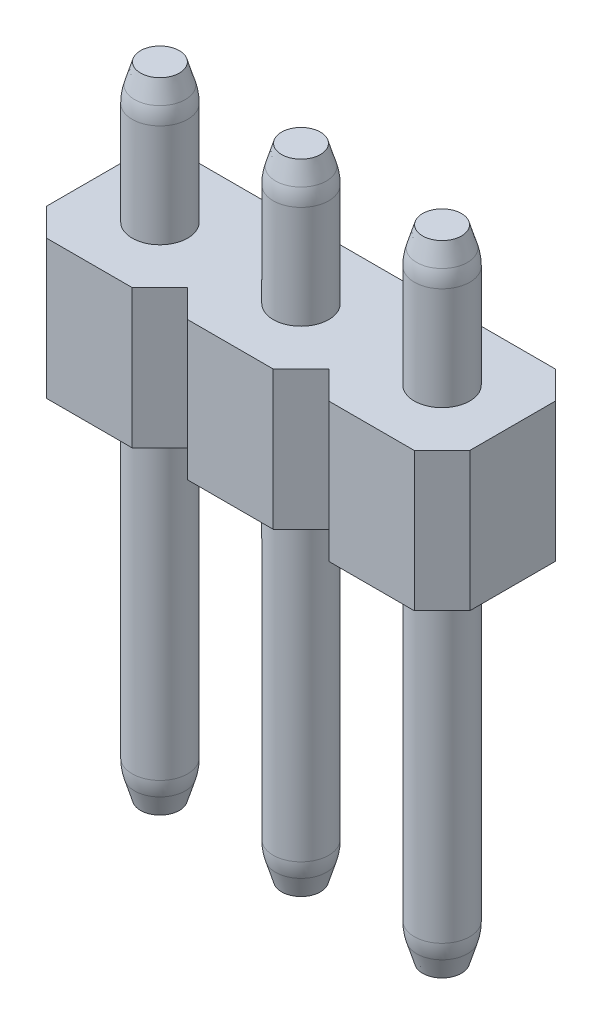
from build123d import *

# Parameters (mm, degrees)
SKETCH1_R               = 0.5
BOSS_EXTRUDE1_DEPTH     = 11.5
BOSS_EXTRUDE1_2_DEPTH   = 11.5
BOSS_EXTRUDE1_3_DEPTH   = 11.5
BOSS_EXTRUDE1_4_DEPTH   = 11.5
BOSS_EXTRUDE1_5_DEPTH   = 11.5
BOSS_EXTRUDE1_6_DEPTH   = 11.5
BOSS_EXTRUDE1_7_DEPTH   = 11.5
BOSS_EXTRUDE1_8_DEPTH   = 11.5
BOSS_EXTRUDE1_9_DEPTH   = 11.5
BOSS_EXTRUDE1_10_DEPTH  = 11.5
BOSS_EXTRUDE1_11_DEPTH  = 11.5
BOSS_EXTRUDE1_12_DEPTH  = 11.5
BOSS_EXTRUDE1_13_DEPTH  = 11.5
BOSS_EXTRUDE1_14_DEPTH  = 11.5
BOSS_EXTRUDE1_15_DEPTH  = 11.5
BOSS_EXTRUDE1_16_DEPTH  = 11.5
BOSS_EXTRUDE2_DEPTH     = 2.5
CHAMFER1_SIZE           = 0.5
CHAMFER1_SIZE2          = 0.15
CHAMFER1_PART_2_SIZE    = 0.5
CHAMFER1_PART_2_SIZE2   = 0.15
CHAMFER1_PART_3_SIZE    = 0.5
CHAMFER1_PART_3_SIZE2   = 0.15
CHAMFER1_PART_4_SIZE    = 0.5
CHAMFER1_PART_4_SIZE2   = 0.15
CHAMFER1_PART_5_SIZE    = 0.5
CHAMFER1_PART_5_SIZE2   = 0.15
CHAMFER1_PART_6_SIZE    = 0.5
CHAMFER1_PART_6_SIZE2   = 0.15
CHAMFER1_PART_7_SIZE    = 0.5
CHAMFER1_PART_7_SIZE2   = 0.15
CHAMFER1_PART_8_SIZE    = 0.5
CHAMFER1_PART_8_SIZE2   = 0.15
CHAMFER1_PART_9_SIZE    = 0.5
CHAMFER1_PART_9_SIZE2   = 0.15
CHAMFER1_PART_10_SIZE   = 0.5
CHAMFER1_PART_10_SIZE2  = 0.15
CHAMFER1_PART_11_SIZE   = 0.5
CHAMFER1_PART_11_SIZE2  = 0.15
CHAMFER1_PART_12_SIZE   = 0.5
CHAMFER1_PART_12_SIZE2  = 0.15
CHAMFER1_PART_13_SIZE   = 0.5
CHAMFER1_PART_13_SIZE2  = 0.15
CHAMFER1_PART_14_SIZE   = 0.5
CHAMFER1_PART_14_SIZE2  = 0.15
CHAMFER1_PART_15_SIZE   = 0.5
CHAMFER1_PART_15_SIZE2  = 0.15
CHAMFER1_PART_16_SIZE   = 0.5
CHAMFER1_PART_16_SIZE2  = 0.15
FILLET1_R               = 1
CHAMFER2_SIZE           = 0.15
CHAMFER2_SIZE2          = 0.5
CHAMFER2_PART_2_SIZE    = 0.15
CHAMFER2_PART_2_SIZE2   = 0.5
CHAMFER2_PART_3_SIZE    = 0.15
CHAMFER2_PART_3_SIZE2   = 0.5
CHAMFER2_PART_4_SIZE    = 0.15
CHAMFER2_PART_4_SIZE2   = 0.5
CHAMFER2_PART_5_SIZE    = 0.15
CHAMFER2_PART_5_SIZE2   = 0.5
CHAMFER2_PART_6_SIZE    = 0.15
CHAMFER2_PART_6_SIZE2   = 0.5
CHAMFER2_PART_7_SIZE    = 0.15
CHAMFER2_PART_7_SIZE2   = 0.5
CHAMFER2_PART_8_SIZE    = 0.15
CHAMFER2_PART_8_SIZE2   = 0.5
CHAMFER2_PART_9_SIZE    = 0.15
CHAMFER2_PART_9_SIZE2   = 0.5
CHAMFER2_PART_10_SIZE   = 0.15
CHAMFER2_PART_10_SIZE2  = 0.5
CHAMFER2_PART_11_SIZE   = 0.15
CHAMFER2_PART_11_SIZE2  = 0.5
CHAMFER2_PART_12_SIZE   = 0.15
CHAMFER2_PART_12_SIZE2  = 0.5
CHAMFER2_PART_13_SIZE   = 0.15
CHAMFER2_PART_13_SIZE2  = 0.5
CHAMFER2_PART_14_SIZE   = 0.15
CHAMFER2_PART_14_SIZE2  = 0.5
CHAMFER2_PART_15_SIZE   = 0.15
CHAMFER2_PART_15_SIZE2  = 0.5
CHAMFER2_PART_16_SIZE   = 0.15
CHAMFER2_PART_16_SIZE2  = 0.5
FILLET2_R               = 1
CUT_EXTRUDE1_DEPTH      = 1
CUT_EXTRUDE1_DEPTH_BACK = 3.54


with BuildPart() as part:
    # Sketch1 → Boss-Extrude1 (new body)
    with BuildSketch(Plane(origin=(0, 0, 0), x_dir=(1, 0, 0), z_dir=(0, 1, 0))):
        Circle(SKETCH1_R)
    extrude(amount=BOSS_EXTRUDE1_DEPTH)



with BuildPart() as body_2:
    # Sketch1 → Boss-Extrude1 2 (new body)
    with BuildSketch(Plane(origin=(0, 0, 0), x_dir=(1, 0, 0), z_dir=(0, 1, 0))):
        with Locations((2.54, 0)):
            Circle(SKETCH1_R)
    extrude(amount=BOSS_EXTRUDE1_2_DEPTH)


with BuildPart() as body_3:
    # Sketch1 → Boss-Extrude1 3 (new body)
    with BuildSketch(Plane(origin=(0, 0, 0), x_dir=(1, 0, 0), z_dir=(0, 1, 0))):
        with Locations((5.08, 0)):
            Circle(SKETCH1_R)
    extrude(amount=BOSS_EXTRUDE1_3_DEPTH)


with BuildPart() as body_4:
    # Sketch1 → Boss-Extrude1 4 (new body)
    with BuildSketch(Plane(origin=(0, 0, 0), x_dir=(1, 0, 0), z_dir=(0, 1, 0))):
        with Locations((7.62, 0)):
            Circle(SKETCH1_R)
    extrude(amount=BOSS_EXTRUDE1_4_DEPTH)


with BuildPart() as body_5:
    # Sketch1 → Boss-Extrude1 5 (new body)
    with BuildSketch(Plane(origin=(0, 0, 0), x_dir=(1, 0, 0), z_dir=(0, 1, 0))):
        with Locations((10.16, 0)):
            Circle(SKETCH1_R)
    extrude(amount=BOSS_EXTRUDE1_5_DEPTH)


with BuildPart() as body_6:
    # Sketch1 → Boss-Extrude1 6 (new body)
    with BuildSketch(Plane(origin=(0, 0, 0), x_dir=(1, 0, 0), z_dir=(0, 1, 0))):
        with Locations((12.7, 0)):
            Circle(SKETCH1_R)
    extrude(amount=BOSS_EXTRUDE1_6_DEPTH)


with BuildPart() as body_7:
    # Sketch1 → Boss-Extrude1 7 (new body)
    with BuildSketch(Plane(origin=(0, 0, 0), x_dir=(1, 0, 0), z_dir=(0, 1, 0))):
        with Locations((15.24, 0)):
            Circle(SKETCH1_R)
    extrude(amount=BOSS_EXTRUDE1_7_DEPTH)


with BuildPart() as body_8:
    # Sketch1 → Boss-Extrude1 8 (new body)
    with BuildSketch(Plane(origin=(0, 0, 0), x_dir=(1, 0, 0), z_dir=(0, 1, 0))):
        with Locations((17.78, 0)):
            Circle(SKETCH1_R)
    extrude(amount=BOSS_EXTRUDE1_8_DEPTH)


with BuildPart() as body_9:
    # Sketch1 → Boss-Extrude1 9 (new body)
    with BuildSketch(Plane(origin=(0, 0, 0), x_dir=(1, 0, 0), z_dir=(0, 1, 0))):
        with Locations((20.32, 0)):
            Circle(SKETCH1_R)
    extrude(amount=BOSS_EXTRUDE1_9_DEPTH)


with BuildPart() as body_10:
    # Sketch1 → Boss-Extrude1 10 (new body)
    with BuildSketch(Plane(origin=(0, 0, 0), x_dir=(1, 0, 0), z_dir=(0, 1, 0))):
        with Locations((22.86, 0)):
            Circle(SKETCH1_R)
    extrude(amount=BOSS_EXTRUDE1_10_DEPTH)


with BuildPart() as body_11:
    # Sketch1 → Boss-Extrude1 11 (new body)
    with BuildSketch(Plane(origin=(0, 0, 0), x_dir=(1, 0, 0), z_dir=(0, 1, 0))):
        with Locations((25.4, 0)):
            Circle(SKETCH1_R)
    extrude(amount=BOSS_EXTRUDE1_11_DEPTH)


with BuildPart() as body_12:
    # Sketch1 → Boss-Extrude1 12 (new body)
    with BuildSketch(Plane(origin=(0, 0, 0), x_dir=(1, 0, 0), z_dir=(0, 1, 0))):
        with Locations((27.94, 0)):
            Circle(SKETCH1_R)
    extrude(amount=BOSS_EXTRUDE1_12_DEPTH)


with BuildPart() as body_13:
    # Sketch1 → Boss-Extrude1 13 (new body)
    with BuildSketch(Plane(origin=(0, 0, 0), x_dir=(1, 0, 0), z_dir=(0, 1, 0))):
        with Locations((30.48, 0)):
            Circle(SKETCH1_R)
    extrude(amount=BOSS_EXTRUDE1_13_DEPTH)


with BuildPart() as body_14:
    # Sketch1 → Boss-Extrude1 14 (new body)
    with BuildSketch(Plane(origin=(0, 0, 0), x_dir=(1, 0, 0), z_dir=(0, 1, 0))):
        with Locations((33.02, 0)):
            Circle(SKETCH1_R)
    extrude(amount=BOSS_EXTRUDE1_14_DEPTH)


with BuildPart() as body_15:
    # Sketch1 → Boss-Extrude1 15 (new body)
    with BuildSketch(Plane(origin=(0, 0, 0), x_dir=(1, 0, 0), z_dir=(0, 1, 0))):
        with Locations((35.56, 0)):
            Circle(SKETCH1_R)
    extrude(amount=BOSS_EXTRUDE1_15_DEPTH)


with BuildPart() as body_16:
    # Sketch1 → Boss-Extrude1 16 (new body)
    with BuildSketch(Plane(origin=(0, 0, 0), x_dir=(1, 0, 0), z_dir=(0, 1, 0))):
        with Locations((38.1, 0)):
            Circle(SKETCH1_R)
    extrude(amount=BOSS_EXTRUDE1_16_DEPTH)


with BuildPart() as part_1:
    add(part.part)

    add(body_2.part)  # Boss-Extrude2 merges body 2

    add(body_3.part)  # Boss-Extrude2 merges body 3

    add(body_4.part)  # Boss-Extrude2 merges body 4

    add(body_5.part)  # Boss-Extrude2 merges body 5

    add(body_6.part)  # Boss-Extrude2 merges body 6

    add(body_7.part)  # Boss-Extrude2 merges body 7

    add(body_8.part)  # Boss-Extrude2 merges body 8

    add(body_9.part)  # Boss-Extrude2 merges body 9

    add(body_10.part)  # Boss-Extrude2 merges body 10

    add(body_11.part)  # Boss-Extrude2 merges body 11

    add(body_12.part)  # Boss-Extrude2 merges body 12

    add(body_13.part)  # Boss-Extrude2 merges body 13

    add(body_14.part)  # Boss-Extrude2 merges body 14

    add(body_15.part)  # Boss-Extrude2 merges body 15

    add(body_16.part)  # Boss-Extrude2 merges body 16
    # Sketch2 → Boss-Extrude2 (add)
    with BuildSketch(Plane(origin=(0, 6.5, 0), x_dir=(1, 0, 0), z_dir=(0, 1, 0))):
        Polygon((-1.27, 0.77), (-0.77, 1.27), (0.77, 1.27), (1.27, 0.77), (1.77, 1.27), (3.31, 1.27), (3.81, 0.77), (4.31, 1.27), (5.85, 1.27), (6.35, 0.77), (6.85, 1.27), (8.39, 1.27), (8.89, 0.77), (9.39, 1.27), (10.93, 1.27), (11.43, 0.77), (11.93, 1.27), (13.47, 1.27), (13.97, 0.77), (14.47, 1.27), (16.01, 1.27), (16.51, 0.77), (17.01, 1.27), (18.55, 1.27), (19.05, 0.77), (19.55, 1.27), (21.09, 1.27), (21.59, 0.77), (22.09, 1.27), (23.63, 1.27), (24.13, 0.77), (24.63, 1.27), (26.17, 1.27), (26.67, 0.77), (27.17, 1.27), (28.71, 1.27), (29.21, 0.77), (29.71, 1.27), (31.25, 1.27), (31.75, 0.77), (32.25, 1.27), (33.79, 1.27), (34.29, 0.77), (34.79, 1.27), (36.33, 1.27), (36.83, 0.77), (37.33, 1.27), (38.87, 1.27), (39.37, 0.77), (39.37, -0.77), (38.87, -1.27), (37.33, -1.27), (36.83, -0.77), (36.33, -1.27), (34.79, -1.27), (34.29, -0.77), (33.79, -1.27), (32.25, -1.27), (31.75, -0.77), (31.25, -1.27), (29.71, -1.27), (29.21, -0.77), (28.71, -1.27), (27.17, -1.27), (26.67, -0.77), (26.17, -1.27), (24.63, -1.27), (24.13, -0.77), (23.63, -1.27), (22.09, -1.27), (21.59, -0.77), (21.09, -1.27), (19.55, -1.27), (19.05, -0.77), (18.55, -1.27), (17.01, -1.27), (16.51, -0.77), (16.01, -1.27), (14.47, -1.27), (13.97, -0.77), (13.47, -1.27), (11.93, -1.27), (11.43, -0.77), (10.93, -1.27), (9.39, -1.27), (8.89, -0.77), (8.39, -1.27), (6.85, -1.27), (6.35, -0.77), (5.85, -1.27), (4.31, -1.27), (3.81, -0.77), (3.31, -1.27), (1.77, -1.27), (1.27, -0.77), (0.77, -1.27), (-0.77, -1.27), (-1.27, -0.77), align=None)
    extrude(amount=BOSS_EXTRUDE2_DEPTH)

    # Chamfer1
    chamfer1_edges = [part_1.edges().sort_by_distance(p)[0] for p in [
        (2.04, 11.5, 0),
    ]]
    chamfer1_side = [part_1.faces().sort_by_distance(p)[0] for p in [
        (2.04, 10.25, 0),
    ]]
    chamfer(chamfer1_edges, length=CHAMFER1_SIZE, length2=CHAMFER1_SIZE2, reference=chamfer1_side[0])

    # Chamfer1 part 2
    chamfer1_part_2_edges = [part_1.edges().sort_by_distance(p)[0] for p in [
        (4.58, 11.5, 0),
    ]]
    chamfer1_part_2_side = [part_1.faces().sort_by_distance(p)[0] for p in [
        (4.58, 10.25, 0),
    ]]
    chamfer(chamfer1_part_2_edges, length=CHAMFER1_PART_2_SIZE, length2=CHAMFER1_PART_2_SIZE2, reference=chamfer1_part_2_side[0])

    # Chamfer1 part 3
    chamfer1_part_3_edges = [part_1.edges().sort_by_distance(p)[0] for p in [
        (7.12, 11.5, 0),
    ]]
    chamfer1_part_3_side = [part_1.faces().sort_by_distance(p)[0] for p in [
        (7.12, 10.25, 0),
    ]]
    chamfer(chamfer1_part_3_edges, length=CHAMFER1_PART_3_SIZE, length2=CHAMFER1_PART_3_SIZE2, reference=chamfer1_part_3_side[0])

    # Chamfer1 part 4
    chamfer1_part_4_edges = [part_1.edges().sort_by_distance(p)[0] for p in [
        (9.66, 11.5, 0),
    ]]
    chamfer1_part_4_side = [part_1.faces().sort_by_distance(p)[0] for p in [
        (9.66, 10.25, 0),
    ]]
    chamfer(chamfer1_part_4_edges, length=CHAMFER1_PART_4_SIZE, length2=CHAMFER1_PART_4_SIZE2, reference=chamfer1_part_4_side[0])

    # Chamfer1 part 5
    chamfer1_part_5_edges = [part_1.edges().sort_by_distance(p)[0] for p in [
        (12.2, 11.5, 0),
    ]]
    chamfer1_part_5_side = [part_1.faces().sort_by_distance(p)[0] for p in [
        (12.2, 10.25, 0),
    ]]
    chamfer(chamfer1_part_5_edges, length=CHAMFER1_PART_5_SIZE, length2=CHAMFER1_PART_5_SIZE2, reference=chamfer1_part_5_side[0])

    # Chamfer1 part 6
    chamfer1_part_6_edges = [part_1.edges().sort_by_distance(p)[0] for p in [
        (14.74, 11.5, 0),
    ]]
    chamfer1_part_6_side = [part_1.faces().sort_by_distance(p)[0] for p in [
        (14.74, 10.25, 0),
    ]]
    chamfer(chamfer1_part_6_edges, length=CHAMFER1_PART_6_SIZE, length2=CHAMFER1_PART_6_SIZE2, reference=chamfer1_part_6_side[0])

    # Chamfer1 part 7
    chamfer1_part_7_edges = [part_1.edges().sort_by_distance(p)[0] for p in [
        (17.28, 11.5, 0),
    ]]
    chamfer1_part_7_side = [part_1.faces().sort_by_distance(p)[0] for p in [
        (17.28, 10.25, 0),
    ]]
    chamfer(chamfer1_part_7_edges, length=CHAMFER1_PART_7_SIZE, length2=CHAMFER1_PART_7_SIZE2, reference=chamfer1_part_7_side[0])

    # Chamfer1 part 8
    chamfer1_part_8_edges = [part_1.edges().sort_by_distance(p)[0] for p in [
        (19.82, 11.5, 0),
    ]]
    chamfer1_part_8_side = [part_1.faces().sort_by_distance(p)[0] for p in [
        (19.82, 10.25, 0),
    ]]
    chamfer(chamfer1_part_8_edges, length=CHAMFER1_PART_8_SIZE, length2=CHAMFER1_PART_8_SIZE2, reference=chamfer1_part_8_side[0])

    # Chamfer1 part 9
    chamfer1_part_9_edges = [part_1.edges().sort_by_distance(p)[0] for p in [
        (22.36, 11.5, 0),
    ]]
    chamfer1_part_9_side = [part_1.faces().sort_by_distance(p)[0] for p in [
        (22.36, 10.25, 0),
    ]]
    chamfer(chamfer1_part_9_edges, length=CHAMFER1_PART_9_SIZE, length2=CHAMFER1_PART_9_SIZE2, reference=chamfer1_part_9_side[0])

    # Chamfer1 part 10
    chamfer1_part_10_edges = [part_1.edges().sort_by_distance(p)[0] for p in [
        (24.9, 11.5, 0),
    ]]
    chamfer1_part_10_side = [part_1.faces().sort_by_distance(p)[0] for p in [
        (24.9, 10.25, 0),
    ]]
    chamfer(chamfer1_part_10_edges, length=CHAMFER1_PART_10_SIZE, length2=CHAMFER1_PART_10_SIZE2, reference=chamfer1_part_10_side[0])

    # Chamfer1 part 11
    chamfer1_part_11_edges = [part_1.edges().sort_by_distance(p)[0] for p in [
        (27.44, 11.5, 0),
    ]]
    chamfer1_part_11_side = [part_1.faces().sort_by_distance(p)[0] for p in [
        (27.44, 10.25, 0),
    ]]
    chamfer(chamfer1_part_11_edges, length=CHAMFER1_PART_11_SIZE, length2=CHAMFER1_PART_11_SIZE2, reference=chamfer1_part_11_side[0])

    # Chamfer1 part 12
    chamfer1_part_12_edges = [part_1.edges().sort_by_distance(p)[0] for p in [
        (29.98, 11.5, 0),
    ]]
    chamfer1_part_12_side = [part_1.faces().sort_by_distance(p)[0] for p in [
        (29.98, 10.25, 0),
    ]]
    chamfer(chamfer1_part_12_edges, length=CHAMFER1_PART_12_SIZE, length2=CHAMFER1_PART_12_SIZE2, reference=chamfer1_part_12_side[0])

    # Chamfer1 part 13
    chamfer1_part_13_edges = [part_1.edges().sort_by_distance(p)[0] for p in [
        (32.52, 11.5, 0),
    ]]
    chamfer1_part_13_side = [part_1.faces().sort_by_distance(p)[0] for p in [
        (32.52, 10.25, 0),
    ]]
    chamfer(chamfer1_part_13_edges, length=CHAMFER1_PART_13_SIZE, length2=CHAMFER1_PART_13_SIZE2, reference=chamfer1_part_13_side[0])

    # Chamfer1 part 14
    chamfer1_part_14_edges = [part_1.edges().sort_by_distance(p)[0] for p in [
        (35.06, 11.5, 0),
    ]]
    chamfer1_part_14_side = [part_1.faces().sort_by_distance(p)[0] for p in [
        (35.06, 10.25, 0),
    ]]
    chamfer(chamfer1_part_14_edges, length=CHAMFER1_PART_14_SIZE, length2=CHAMFER1_PART_14_SIZE2, reference=chamfer1_part_14_side[0])

    # Chamfer1 part 15
    chamfer1_part_15_edges = [part_1.edges().sort_by_distance(p)[0] for p in [
        (37.6, 11.5, 0),
    ]]
    chamfer1_part_15_side = [part_1.faces().sort_by_distance(p)[0] for p in [
        (37.6, 10.25, 0),
    ]]
    chamfer(chamfer1_part_15_edges, length=CHAMFER1_PART_15_SIZE, length2=CHAMFER1_PART_15_SIZE2, reference=chamfer1_part_15_side[0])

    # Chamfer1 part 16
    chamfer1_part_16_edges = [part_1.edges().sort_by_distance(p)[0] for p in [
        (-0.5, 11.5, 0),
    ]]
    chamfer1_part_16_side = [part_1.faces().sort_by_distance(p)[0] for p in [
        (-0.5, 10.25, 0),
    ]]
    chamfer(chamfer1_part_16_edges, length=CHAMFER1_PART_16_SIZE, length2=CHAMFER1_PART_16_SIZE2, reference=chamfer1_part_16_side[0])

    # Fillet1
    fillet1_edges = [part_1.edges().sort_by_distance(p)[0] for p in [
        (37.6, 11, 0),
        (35.06, 11, 0),
        (32.52, 11, 0),
        (29.98, 11, 0),
        (27.44, 11, 0),
        (24.9, 11, 0),
        (22.36, 11, 0),
        (19.82, 11, 0),
        (17.28, 11, 0),
        (14.74, 11, 0),
        (12.2, 11, 0),
        (9.66, 11, 0),
        (7.12, 11, 0),
        (4.58, 11, 0),
        (2.04, 11, 0),
        (-0.5, 11, 0),
    ]]
    fillet(fillet1_edges, radius=FILLET1_R)

    # Chamfer2
    chamfer2_edges = [part_1.edges().sort_by_distance(p)[0] for p in [
        (-0.5, 0, 0),
    ]]
    chamfer2_side = [part_1.faces().sort_by_distance(p)[0] for p in [
        (0, 0, 0),
    ]]
    chamfer(chamfer2_edges, length=CHAMFER2_SIZE, length2=CHAMFER2_SIZE2, reference=chamfer2_side[0])

    # Chamfer2 part 2
    chamfer2_part_2_edges = [part_1.edges().sort_by_distance(p)[0] for p in [
        (2.04, 0, 0),
    ]]
    chamfer2_part_2_side = [part_1.faces().sort_by_distance(p)[0] for p in [
        (2.54, 0, 0),
    ]]
    chamfer(chamfer2_part_2_edges, length=CHAMFER2_PART_2_SIZE, length2=CHAMFER2_PART_2_SIZE2, reference=chamfer2_part_2_side[0])

    # Chamfer2 part 3
    chamfer2_part_3_edges = [part_1.edges().sort_by_distance(p)[0] for p in [
        (4.58, 0, 0),
    ]]
    chamfer2_part_3_side = [part_1.faces().sort_by_distance(p)[0] for p in [
        (5.08, 0, 0),
    ]]
    chamfer(chamfer2_part_3_edges, length=CHAMFER2_PART_3_SIZE, length2=CHAMFER2_PART_3_SIZE2, reference=chamfer2_part_3_side[0])

    # Chamfer2 part 4
    chamfer2_part_4_edges = [part_1.edges().sort_by_distance(p)[0] for p in [
        (7.12, 0, 0),
    ]]
    chamfer2_part_4_side = [part_1.faces().sort_by_distance(p)[0] for p in [
        (7.62, 0, 0),
    ]]
    chamfer(chamfer2_part_4_edges, length=CHAMFER2_PART_4_SIZE, length2=CHAMFER2_PART_4_SIZE2, reference=chamfer2_part_4_side[0])

    # Chamfer2 part 5
    chamfer2_part_5_edges = [part_1.edges().sort_by_distance(p)[0] for p in [
        (9.66, 0, 0),
    ]]
    chamfer2_part_5_side = [part_1.faces().sort_by_distance(p)[0] for p in [
        (10.16, 0, 0),
    ]]
    chamfer(chamfer2_part_5_edges, length=CHAMFER2_PART_5_SIZE, length2=CHAMFER2_PART_5_SIZE2, reference=chamfer2_part_5_side[0])

    # Chamfer2 part 6
    chamfer2_part_6_edges = [part_1.edges().sort_by_distance(p)[0] for p in [
        (12.2, 0, 0),
    ]]
    chamfer2_part_6_side = [part_1.faces().sort_by_distance(p)[0] for p in [
        (12.7, 0, 0),
    ]]
    chamfer(chamfer2_part_6_edges, length=CHAMFER2_PART_6_SIZE, length2=CHAMFER2_PART_6_SIZE2, reference=chamfer2_part_6_side[0])

    # Chamfer2 part 7
    chamfer2_part_7_edges = [part_1.edges().sort_by_distance(p)[0] for p in [
        (14.74, 0, 0),
    ]]
    chamfer2_part_7_side = [part_1.faces().sort_by_distance(p)[0] for p in [
        (15.24, 0, 0),
    ]]
    chamfer(chamfer2_part_7_edges, length=CHAMFER2_PART_7_SIZE, length2=CHAMFER2_PART_7_SIZE2, reference=chamfer2_part_7_side[0])

    # Chamfer2 part 8
    chamfer2_part_8_edges = [part_1.edges().sort_by_distance(p)[0] for p in [
        (17.28, 0, 0),
    ]]
    chamfer2_part_8_side = [part_1.faces().sort_by_distance(p)[0] for p in [
        (17.78, 0, 0),
    ]]
    chamfer(chamfer2_part_8_edges, length=CHAMFER2_PART_8_SIZE, length2=CHAMFER2_PART_8_SIZE2, reference=chamfer2_part_8_side[0])

    # Chamfer2 part 9
    chamfer2_part_9_edges = [part_1.edges().sort_by_distance(p)[0] for p in [
        (19.82, 0, 0),
    ]]
    chamfer2_part_9_side = [part_1.faces().sort_by_distance(p)[0] for p in [
        (20.32, 0, 0),
    ]]
    chamfer(chamfer2_part_9_edges, length=CHAMFER2_PART_9_SIZE, length2=CHAMFER2_PART_9_SIZE2, reference=chamfer2_part_9_side[0])

    # Chamfer2 part 10
    chamfer2_part_10_edges = [part_1.edges().sort_by_distance(p)[0] for p in [
        (22.36, 0, 0),
    ]]
    chamfer2_part_10_side = [part_1.faces().sort_by_distance(p)[0] for p in [
        (22.86, 0, 0),
    ]]
    chamfer(chamfer2_part_10_edges, length=CHAMFER2_PART_10_SIZE, length2=CHAMFER2_PART_10_SIZE2, reference=chamfer2_part_10_side[0])

    # Chamfer2 part 11
    chamfer2_part_11_edges = [part_1.edges().sort_by_distance(p)[0] for p in [
        (24.9, 0, 0),
    ]]
    chamfer2_part_11_side = [part_1.faces().sort_by_distance(p)[0] for p in [
        (25.4, 0, 0),
    ]]
    chamfer(chamfer2_part_11_edges, length=CHAMFER2_PART_11_SIZE, length2=CHAMFER2_PART_11_SIZE2, reference=chamfer2_part_11_side[0])

    # Chamfer2 part 12
    chamfer2_part_12_edges = [part_1.edges().sort_by_distance(p)[0] for p in [
        (27.44, 0, 0),
    ]]
    chamfer2_part_12_side = [part_1.faces().sort_by_distance(p)[0] for p in [
        (27.94, 0, 0),
    ]]
    chamfer(chamfer2_part_12_edges, length=CHAMFER2_PART_12_SIZE, length2=CHAMFER2_PART_12_SIZE2, reference=chamfer2_part_12_side[0])

    # Chamfer2 part 13
    chamfer2_part_13_edges = [part_1.edges().sort_by_distance(p)[0] for p in [
        (29.98, 0, 0),
    ]]
    chamfer2_part_13_side = [part_1.faces().sort_by_distance(p)[0] for p in [
        (30.48, 0, 0),
    ]]
    chamfer(chamfer2_part_13_edges, length=CHAMFER2_PART_13_SIZE, length2=CHAMFER2_PART_13_SIZE2, reference=chamfer2_part_13_side[0])

    # Chamfer2 part 14
    chamfer2_part_14_edges = [part_1.edges().sort_by_distance(p)[0] for p in [
        (32.52, 0, 0),
    ]]
    chamfer2_part_14_side = [part_1.faces().sort_by_distance(p)[0] for p in [
        (33.02, 0, 0),
    ]]
    chamfer(chamfer2_part_14_edges, length=CHAMFER2_PART_14_SIZE, length2=CHAMFER2_PART_14_SIZE2, reference=chamfer2_part_14_side[0])

    # Chamfer2 part 15
    chamfer2_part_15_edges = [part_1.edges().sort_by_distance(p)[0] for p in [
        (35.06, 0, 0),
    ]]
    chamfer2_part_15_side = [part_1.faces().sort_by_distance(p)[0] for p in [
        (35.56, 0, 0),
    ]]
    chamfer(chamfer2_part_15_edges, length=CHAMFER2_PART_15_SIZE, length2=CHAMFER2_PART_15_SIZE2, reference=chamfer2_part_15_side[0])

    # Chamfer2 part 16
    chamfer2_part_16_edges = [part_1.edges().sort_by_distance(p)[0] for p in [
        (37.6, 0, 0),
    ]]
    chamfer2_part_16_side = [part_1.faces().sort_by_distance(p)[0] for p in [
        (38.1, 0, 0),
    ]]
    chamfer(chamfer2_part_16_edges, length=CHAMFER2_PART_16_SIZE, length2=CHAMFER2_PART_16_SIZE2, reference=chamfer2_part_16_side[0])

    # Fillet2
    fillet2_edges = [part_1.edges().sort_by_distance(p)[0] for p in [
        (9.66, 0.5, 0),
        (17.28, 0.5, 0),
        (22.36, 0.5, 0),
        (27.44, 0.5, 0),
        (29.98, 0.5, 0),
        (-0.5, 0.5, 0),
        (2.04, 0.5, 0),
        (4.58, 0.5, 0),
        (7.12, 0.5, 0),
        (12.2, 0.5, 0),
        (14.74, 0.5, 0),
        (19.82, 0.5, 0),
        (24.9, 0.5, 0),
        (32.52, 0.5, 0),
        (35.06, 0.5, 0),
        (37.6, 0.5, 0),
    ]]
    fillet(fillet2_edges, radius=FILLET2_R)

    # Sketch3 → Cut-Extrude1 (cut, two sides)
    with BuildSketch(Plane(origin=(0, 0, -1.27), x_dir=(-1, 0, 0), z_dir=(0, 0, -1))) as cut_extrude1_sk:
        Polygon((-31.75, 11.5), (-31.75, 0), (-40.282511818, 0), (-40.282511818, 14.702627998), align=None)
        Polygon((-24.13, 11.5), (-24.13, 0), (2.40719131, -1.427988579), (2.361545608, 11.5), align=None)
    extrude(amount=CUT_EXTRUDE1_DEPTH, mode=Mode.SUBTRACT)
    extrude(cut_extrude1_sk.sketch, amount=-CUT_EXTRUDE1_DEPTH_BACK, mode=Mode.SUBTRACT)


solid = part_1.part
